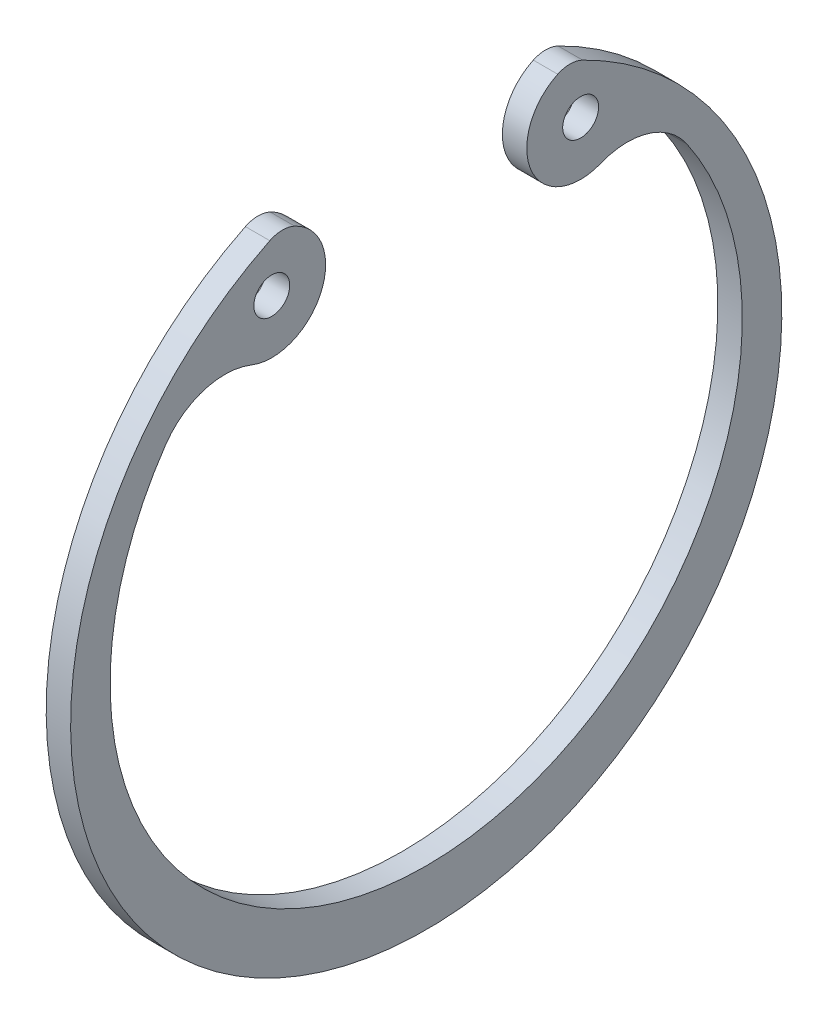
from build123d import *

# Parameters (mm, degrees)
SKETCH_1_R      = 1.25
EXTRUDE_1_DEPTH = 1.7


with BuildPart() as part:
    # Эскиз1 → Бобышка-Вытянуть1 (new body)
    with BuildSketch(Plane(origin=(0, 0, 0), x_dir=(0, 0, -1), z_dir=(1, 0, 0))):
        with BuildLine():
            ThreePointArc((-10.884792801, 22.227995539), (0, -24.75), (10.884792801, 22.227995539))
            ThreePointArc((10.884792801, 22.227995539), (10.021540765, 22.431727234), (9.155077538, 22.242116696))
            ThreePointArc((9.155077538, 22.242116696), (7.311355918, 17.353467341), (12.145333072, 15.370825971))
            ThreePointArc((12.145333072, 15.370825971), (15.454308904, 15.51747296), (18.128902676, 13.563662694))
            ThreePointArc((18.128902676, 13.563662694), (0, -20.9), (-18.128902676, 13.563662694))
            ThreePointArc((-18.128902676, 13.563662694), (-15.454308904, 15.51747296), (-12.145333072, 15.370825971))
            ThreePointArc((-12.145333072, 15.370825971), (-7.311355918, 17.353467341), (-9.155077538, 22.242116696))
            ThreePointArc((-9.155077538, 22.242116696), (-10.021540765, 22.431727234), (-10.884792801, 22.227995539))
        make_face()
        with Locations((10.748404378, 18.84920571)):
            Circle(SKETCH_1_R, mode=Mode.SUBTRACT)
        with Locations((-10.748404378, 18.84920571)):
            Circle(SKETCH_1_R, mode=Mode.SUBTRACT)
    extrude(amount=EXTRUDE_1_DEPTH)


solid = part.part
